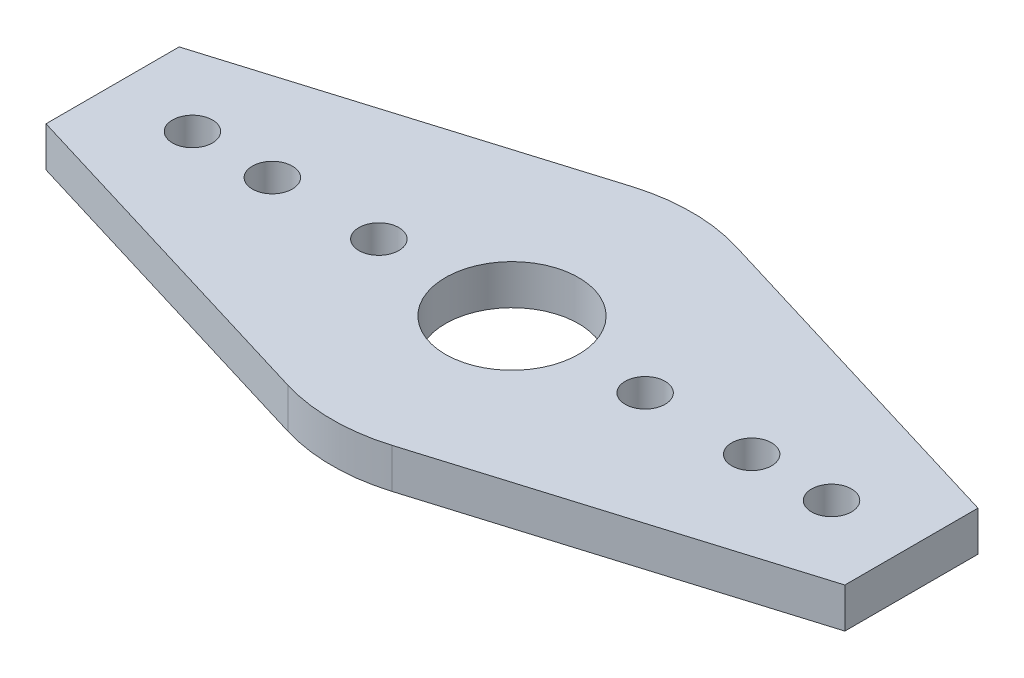
from build123d import *

# Parameters (mm, degrees)
BOSS_EXTRUDE1_DEPTH = 3


with BuildPart() as part:
    # Sketch1 → Boss-Extrude1 (new body)
    with BuildSketch(Plane(origin=(0, 0, 0), x_dir=(1, 0, 0), z_dir=(0, 1, 0))):
        with BuildLine():
            Line((0, -8.5), (0, 0))
            ThreePointArc((0, 0), (-1.982516962, -0.146362799), (-3.922046259, -0.582277556))
            ThreePointArc((-3.922046259, -0.582277556), (-10.844298606, -5.459403769), (-13.5, -13.5))
            Line((-13.5, -13.5), (-11.5, -13.5))
            ThreePointArc((-11.5, -13.5), (-10, -12), (-8.5, -13.5))
            Line((-8.5, -13.5), (-5, -13.5))
            ThreePointArc((-5, -13.5), (-3.535533906, -9.964466094), (0, -8.5))
        make_face()
        with BuildLine():
            ThreePointArc((0, -18.5), (-3.535533906, -17.035533906), (-5, -13.5))
            Line((-5, -13.5), (-8.5, -13.5))
            ThreePointArc((-8.5, -13.5), (-10, -15), (-11.5, -13.5))
            Line((-11.5, -13.5), (-13.5, -13.5))
            ThreePointArc((-13.5, -13.5), (-10.844298606, -21.540596231), (-3.922046259, -26.417722444))
            ThreePointArc((-3.922046259, -26.417722444), (-1.982516962, -26.853637201), (0, -27))
            Line((0, -27), (0, -18.5))
        make_face()
        with BuildLine():
            ThreePointArc((-13.5, -13.5), (-10.844298606, -5.459403769), (-3.922046259, -0.582277556))
            Line((-3.922046259, -0.582277556), (-30, -8.5))
            Line((-30, -8.5), (-30, -13.5))
            Line((-30, -13.5), (-25.5, -13.5))
            ThreePointArc((-25.5, -13.5), (-24, -12), (-22.5, -13.5))
            Line((-22.5, -13.5), (-19.5, -13.5))
            ThreePointArc((-19.5, -13.5), (-18, -12), (-16.5, -13.5))
            Line((-16.5, -13.5), (-13.5, -13.5))
        make_face()
        with BuildLine():
            ThreePointArc((-3.922046259, -26.417722444), (-10.844298606, -21.540596231), (-13.5, -13.5))
            Line((-13.5, -13.5), (-16.5, -13.5))
            ThreePointArc((-16.5, -13.5), (-18, -15), (-19.5, -13.5))
            Line((-19.5, -13.5), (-22.5, -13.5))
            ThreePointArc((-22.5, -13.5), (-24, -15), (-25.5, -13.5))
            Line((-25.5, -13.5), (-30, -13.5))
            Line((-30, -13.5), (-30, -18.5))
            Line((-30, -18.5), (-3.922046259, -26.417722444))
        make_face()
        with BuildLine():
            ThreePointArc((3.922046259, -0.582277556), (1.982516962, -0.146362799), (0, 0))
            Line((0, 0), (0, -8.5))
            ThreePointArc((0, -8.5), (3.535533906, -9.964466094), (5, -13.5))
            Line((5, -13.5), (8.5, -13.5))
            ThreePointArc((8.5, -13.5), (10, -12), (11.5, -13.5))
            Line((11.5, -13.5), (13.5, -13.5))
            ThreePointArc((13.5, -13.5), (10.844298606, -5.459403769), (3.922046259, -0.582277556))
        make_face()
        with BuildLine():
            Line((8.5, -13.5), (5, -13.5))
            ThreePointArc((5, -13.5), (3.535533906, -17.035533906), (0, -18.5))
            Line((0, -18.5), (0, -27))
            ThreePointArc((0, -27), (1.982516962, -26.853637201), (3.922046259, -26.417722444))
            ThreePointArc((3.922046259, -26.417722444), (10.844298606, -21.540596231), (13.5, -13.5))
            Line((13.5, -13.5), (11.5, -13.5))
            ThreePointArc((11.5, -13.5), (10, -15), (8.5, -13.5))
        make_face()
        with BuildLine():
            Line((16.5, -13.5), (13.5, -13.5))
            ThreePointArc((13.5, -13.5), (10.844298606, -21.540596231), (3.922046259, -26.417722444))
            Line((3.922046259, -26.417722444), (30, -18.5))
            Line((30, -18.5), (30, -13.5))
            Line((30, -13.5), (25.5, -13.5))
            ThreePointArc((25.5, -13.5), (24, -15), (22.5, -13.5))
            Line((22.5, -13.5), (19.5, -13.5))
            ThreePointArc((19.5, -13.5), (18, -15), (16.5, -13.5))
        make_face()
        with BuildLine():
            Line((30, -8.5), (3.922046259, -0.582277556))
            ThreePointArc((3.922046259, -0.582277556), (10.844298606, -5.459403769), (13.5, -13.5))
            Line((13.5, -13.5), (16.5, -13.5))
            ThreePointArc((16.5, -13.5), (18, -12), (19.5, -13.5))
            Line((19.5, -13.5), (22.5, -13.5))
            ThreePointArc((22.5, -13.5), (24, -12), (25.5, -13.5))
            Line((25.5, -13.5), (30, -13.5))
            Line((30, -13.5), (30, -8.5))
        make_face()
    extrude(amount=BOSS_EXTRUDE1_DEPTH)


solid = part.part
